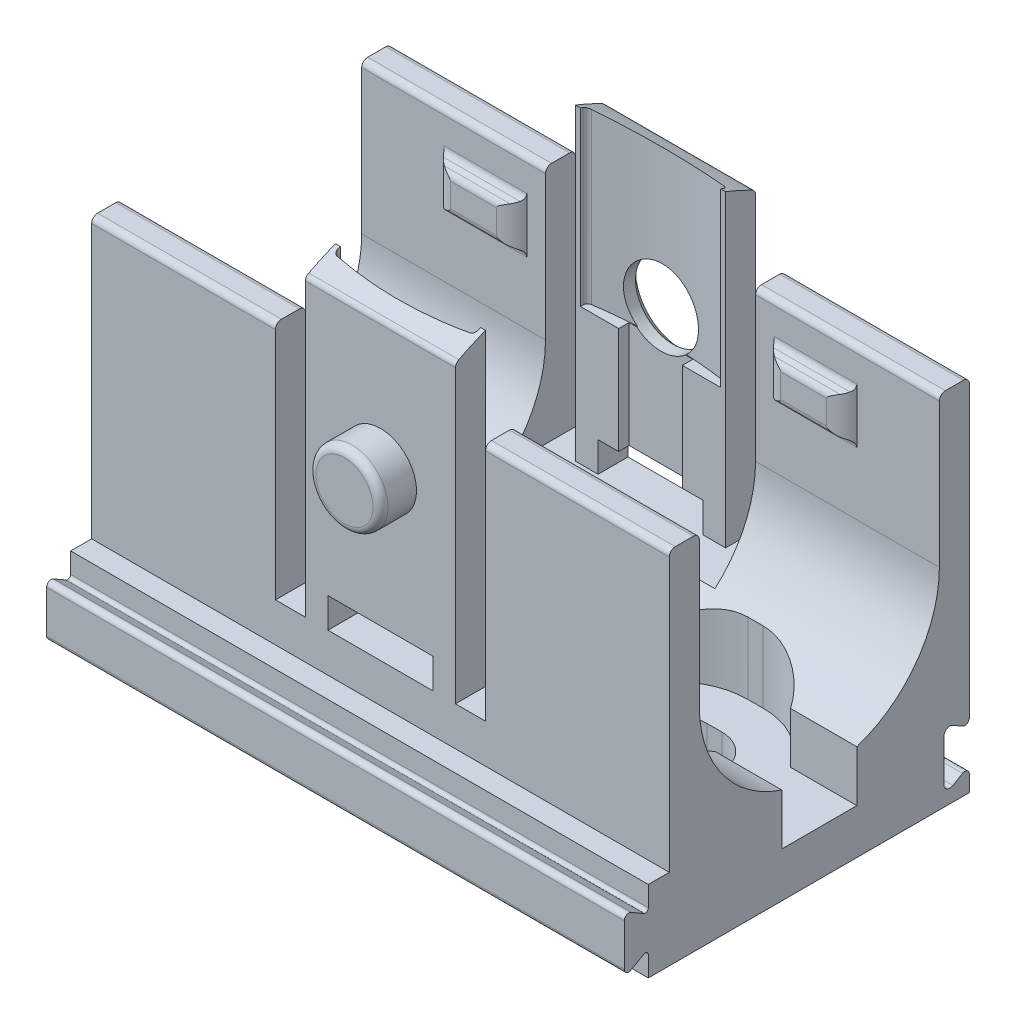
from build123d import *

# Parameters (mm, degrees)
BOSS_EXTRUDE1_DEPTH      = 19.25
BOSS_EXTRUDE1_DEPTH_BACK = 19.25
CUT_EXTRUDE1_DEPTH       = 12
CUT_EXTRUDE1_DEPTH_BACK  = 12
SKETCH2_W                = 14
SKETCH2_H                = 25
BOSS_EXTRUDE2_DEPTH      = 5
BOSS_EXTRUDE2_DEPTH_BACK = 5
BOSS_EXTRUDE3_DEPTH      = 5
BOSS_EXTRUDE3_DEPTH_BACK = 5
CUT_EXTRUDE2_DEPTH       = 12
CUT_EXTRUDE2_DEPTH_BACK  = 12
SKETCH5_W                = 7
SKETCH5_H                = 2
BOSS_EXTRUDE4_DEPTH      = 5.5
BOSS_EXTRUDE5_DEPTH      = 5.5
BOSS_EXTRUDE6_START      = -5.5
BOSS_EXTRUDE6_DEPTH      = 5.5
BOSS_EXTRUDE7_START      = -5.5
BOSS_EXTRUDE7_DEPTH      = 5.5
CUT_EXTRUDE3_DEPTH       = 7
CUT_EXTRUDE4_DEPTH       = 7
CUT_EXTRUDE5_DEPTH       = 2.5
CUT_EXTRUDE5_DEPTH_BACK  = 2.5
CUT_EXTRUDE6_DEPTH       = 2.5
CUT_EXTRUDE6_DEPTH_BACK  = 2.5
CUT_EXTRUDE7_DEPTH       = 2.5
CUT_EXTRUDE7_DEPTH_BACK  = 2.5
CUT_EXTRUDE8_DEPTH       = 2.5
CUT_EXTRUDE8_DEPTH_BACK  = 2.5
SKETCH18_W               = 36.5
SKETCH18_H               = 15.3
CUT_EXTRUDE9_DEPTH       = 1.5
CUT_EXTRUDE10_DEPTH      = 15
SKETCH20_W               = 4.25
SKETCH20_H               = 17.4
CUT_EXTRUDE11_DEPTH      = 8
CUT_EXTRUDE12_DEPTH      = 7
CUT_EXTRUDE13_DEPTH      = 7
BOSS_EXTRUDE8_DEPTH      = 1.5
CUT_EXTRUDE14_DEPTH      = 4
BOSS_EXTRUDE9_DEPTH      = 1.5


with BuildPart() as part:
    # Sketch1 → Boss-Extrude1 (new, two sides: drawn at the far end of the back side and taken through both)
    with BuildSketch(Plane(origin=(0, 0, 0), x_dir=(0, 0, -1), z_dir=(1, 0, 0)).offset(-BOSS_EXTRUDE1_DEPTH_BACK)):
        with BuildLine():
            Line((-13, 4.104145188), (-13, 1.295854812))
            ThreePointArc((-13, 1.295854812), (-12.85, 1.03604719), (-12.55, 1.03604719))
            Line((-12.55, 1.03604719), (-11.7, 1.526794919))
            ThreePointArc((-11.7, 1.526794919), (-11.5, 1.526794919), (-11.4, 1.353589838))
            Line((-11.4, 1.353589838), (-11.4, 0))
            Line((-11.4, 0), (10, 0))
            Line((10, 0), (10, 1.080384758))
            ThreePointArc((10, 1.080384758), (9.85, 1.340192379), (9.55, 1.340192379))
            Line((9.55, 1.340192379), (8.9, 0.964914704))
            ThreePointArc((8.9, 0.964914704), (8.5, 0.964914704), (8.3, 1.311324865))
            Line((8.3, 1.311324865), (8.3, 4.088675135))
            ThreePointArc((8.3, 4.088675135), (8.5, 4.435085296), (8.9, 4.435085296))
            Line((8.9, 4.435085296), (9.55, 4.059807621))
            ThreePointArc((9.55, 4.059807621), (9.85, 4.059807621), (10, 4.319615242))
            Line((10, 4.319615242), (10, 23.6))
            ThreePointArc((10, 23.6), (9.882842712, 23.882842712), (9.6, 24))
            Line((9.6, 24), (8.4, 24))
            ThreePointArc((8.4, 24), (8.117157288, 23.882842712), (8, 23.6))
            Line((8, 23.6), (8, 14))
            ThreePointArc((8, 14), (0, 6), (-8, 14))
            Line((-8, 14), (-8, 23.6))
            ThreePointArc((-8, 23.6), (-8.117157288, 23.882842712), (-8.4, 24))
            Line((-8.4, 24), (-9.6, 24))
            ThreePointArc((-9.6, 24), (-9.882842712, 23.882842712), (-10, 23.6))
            Line((-10, 23.6), (-10, 5.4))
            Line((-10, 5.4), (-11.4, 5.4))
            Line((-11.4, 5.4), (-11.4, 4.046410162))
            ThreePointArc((-11.4, 4.046410162), (-11.5, 3.873205081), (-11.7, 3.873205081))
            Line((-11.7, 3.873205081), (-12.55, 4.36395281))
            ThreePointArc((-12.55, 4.36395281), (-12.85, 4.36395281), (-13, 4.104145188))
        make_face()
    extrude(amount=BOSS_EXTRUDE1_DEPTH + BOSS_EXTRUDE1_DEPTH_BACK)

    # Sketch2 → Cut-Extrude1 (cut, two sides: drawn at the far end of the back side and taken through both)
    with BuildSketch(Plane.XY.offset(-CUT_EXTRUDE1_DEPTH_BACK)):
        with Locations((0, 20.5)):
            Rectangle(SKETCH2_W, SKETCH2_H)
    extrude(amount=CUT_EXTRUDE1_DEPTH + CUT_EXTRUDE1_DEPTH_BACK, mode=Mode.SUBTRACT)

    # Sketch3 → Boss-Extrude2 (add, two sides: drawn at the far end of the back side and taken through both)
    with BuildSketch(Plane(origin=(0, 0, 0), x_dir=(0, 0, -1), z_dir=(1, 0, 0)).offset(-BOSS_EXTRUDE2_DEPTH_BACK)):
        with BuildLine():
            Line((8, 28.563897926), (8, 8))
            Line((8, 8), (10, 8))
            Line((10, 8), (10, 27.401851761))
            ThreePointArc((10, 27.401851761), (9.940919964, 27.611073122), (9.78113211, 27.758490456))
            ThreePointArc((9.78113211, 27.758490456), (8.89968174, 28.181353229), (8, 28.563897926))
        make_face()
    extrude(amount=BOSS_EXTRUDE2_DEPTH + BOSS_EXTRUDE2_DEPTH_BACK)

    # Sketch4 → Boss-Extrude3 (add, two sides: drawn at the far end of the back side and taken through both)
    with BuildSketch(Plane(origin=(0, 0, 0), x_dir=(0, 0, -1), z_dir=(1, 0, 0)).offset(-BOSS_EXTRUDE3_DEPTH_BACK)):
        with BuildLine():
            Line((-10, 27.401851761), (-10, 8))
            Line((-10, 8), (-8, 8))
            Line((-8, 8), (-8, 28.563897926))
            ThreePointArc((-8, 28.563897926), (-8.899681723, 28.181353237), (-9.781132075, 27.758490474))
            ThreePointArc((-9.781132075, 27.758490474), (-9.940919954, 27.611073139), (-10, 27.401851761))
        make_face()
    extrude(amount=BOSS_EXTRUDE3_DEPTH + BOSS_EXTRUDE3_DEPTH_BACK)

    # Sketch5 → Cut-Extrude2 (cut, two sides: drawn at the far end of the back side and taken through both)
    with BuildSketch(Plane.XY.offset(-CUT_EXTRUDE2_DEPTH_BACK)):
        with Locations((0, 9)):
            Rectangle(SKETCH5_W, SKETCH5_H)
    extrude(amount=CUT_EXTRUDE2_DEPTH + CUT_EXTRUDE2_DEPTH_BACK, mode=Mode.SUBTRACT)

    # Sketch6 → Revolve1 (revolve)
    with BuildSketch(Plane(origin=(0, 0, 0), x_dir=(0, 0, -1), z_dir=(1, 0, 0))):
        with BuildLine():
            Line((-12.4, 19), (-12.4, 20.9))
            ThreePointArc((-12.4, 20.9), (-12.253553391, 21.253553391), (-11.9, 21.4))
            Line((-11.9, 21.4), (-10, 21.4))
            Line((-10, 21.4), (-10, 19))
            Line((-10, 19), (-12.4, 19))
        make_face()
    revolve(axis=Axis((0, 19, 10), (0, 0, 1)))

    # Sketch7 → Cut-Revolve1 (revolve, cut)
    with BuildSketch(Plane(origin=(0, 0, 0), x_dir=(0, 0, -1), z_dir=(1, 0, 0))):
        Polygon((8, 19), (8, 21.5), (9.5, 21.5), (10, 22), (10, 19), align=None)
    revolve(axis=Axis((0, 19, -10), (0, 0, 1)), mode=Mode.SUBTRACT)

    # Sketch8 → Boss-Extrude4 (add)
    with BuildSketch(Plane(origin=(8.25, 0, 0), x_dir=(0, 0, -1), z_dir=(1, 0, 0))):
        with BuildLine():
            Line((7.2, 20.79944465), (7.2, 19.20055535))
            ThreePointArc((7.2, 19.20055535), (7.266987298, 18.95055535), (7.45, 18.767542648))
            Line((7.45, 18.767542648), (7.75, 18.594337567))
            ThreePointArc((7.75, 18.594337567), (7.933012702, 18.411324865), (8, 18.161324865))
            Line((8, 18.161324865), (8, 21.838675135))
            ThreePointArc((8, 21.838675135), (7.933012702, 21.588675135), (7.75, 21.405662433))
            Line((7.75, 21.405662433), (7.45, 21.232457352))
            ThreePointArc((7.45, 21.232457352), (7.266987298, 21.04944465), (7.2, 20.79944465))
        make_face()
    extrude(amount=BOSS_EXTRUDE4_DEPTH)

    # Sketch9 → Boss-Extrude5 (add)
    with BuildSketch(Plane(origin=(8.25, 0, 0), x_dir=(0, 0, -1), z_dir=(1, 0, 0))):
        with BuildLine():
            Line((-7.75, 18.594337567), (-7.45, 18.767542648))
            ThreePointArc((-7.45, 18.767542648), (-7.266987298, 18.95055535), (-7.2, 19.20055535))
            Line((-7.2, 19.20055535), (-7.2, 20.79944465))
            ThreePointArc((-7.2, 20.79944465), (-7.266987298, 21.04944465), (-7.45, 21.232457352))
            Line((-7.45, 21.232457352), (-7.75, 21.405662433))
            ThreePointArc((-7.75, 21.405662433), (-7.933012702, 21.588675135), (-8, 21.838675135))
            Line((-8, 21.838675135), (-8, 18.161324865))
            ThreePointArc((-8, 18.161324865), (-7.933012702, 18.411324865), (-7.75, 18.594337567))
        make_face()
    extrude(amount=BOSS_EXTRUDE5_DEPTH)

    # Sketch10 → Boss-Extrude6 (add)
    with BuildSketch(Plane(origin=(-8.25, 0, 0), x_dir=(0, 0, -1), z_dir=(1, 0, 0)).offset(BOSS_EXTRUDE6_START)):
        with BuildLine():
            Line((7.2, 20.79944465), (7.2, 19.20055535))
            ThreePointArc((7.2, 19.20055535), (7.266987298, 18.95055535), (7.45, 18.767542648))
            Line((7.45, 18.767542648), (7.75, 18.594337567))
            ThreePointArc((7.75, 18.594337567), (7.933012702, 18.411324865), (8, 18.161324865))
            Line((8, 18.161324865), (8, 21.838675135))
            ThreePointArc((8, 21.838675135), (7.933012702, 21.588675135), (7.75, 21.405662433))
            Line((7.75, 21.405662433), (7.45, 21.232457352))
            ThreePointArc((7.45, 21.232457352), (7.266987298, 21.04944465), (7.2, 20.79944465))
        make_face()
    extrude(amount=BOSS_EXTRUDE6_DEPTH)

    # Sketch11 → Boss-Extrude7 (add)
    with BuildSketch(Plane(origin=(-8.25, 0, 0), x_dir=(0, 0, -1), z_dir=(1, 0, 0)).offset(BOSS_EXTRUDE7_START)):
        with BuildLine():
            Line((-7.75, 18.594337567), (-7.45, 18.767542648))
            ThreePointArc((-7.45, 18.767542648), (-7.266987298, 18.95055535), (-7.2, 19.20055535))
            Line((-7.2, 19.20055535), (-7.2, 20.79944465))
            ThreePointArc((-7.2, 20.79944465), (-7.266987298, 21.04944465), (-7.45, 21.232457352))
            Line((-7.45, 21.232457352), (-7.75, 21.405662433))
            ThreePointArc((-7.75, 21.405662433), (-7.933012702, 21.588675135), (-8, 21.838675135))
            Line((-8, 21.838675135), (-8, 18.161324865))
            ThreePointArc((-8, 18.161324865), (-7.933012702, 18.411324865), (-7.75, 18.594337567))
        make_face()
    extrude(amount=BOSS_EXTRUDE7_DEPTH)

    # Sketch12 → Cut-Extrude3 (cut)
    with BuildSketch(Plane(origin=(0, 3, 0), x_dir=(1, 0, 0), z_dir=(0, 1, 0))):
        with BuildLine():
            Line((9.5, -5), (10.5, -5))
            ThreePointArc((10.5, -5), (13, -4.330127019), (14.830127019, -2.5))
            Line((14.830127019, -2.5), (19.25, -2.5))
            Line((19.25, -2.5), (19.25, 2.5))
            Line((19.25, 2.5), (14.830127019, 2.5))
            ThreePointArc((14.830127019, 2.5), (13, 4.330127019), (10.5, 5))
            Line((10.5, 5), (9.5, 5))
            ThreePointArc((9.5, 5), (4.5, 0), (9.5, -5))
        make_face()
    extrude(amount=CUT_EXTRUDE3_DEPTH, mode=Mode.SUBTRACT)

    # Sketch13 → Cut-Extrude4 (cut)
    with BuildSketch(Plane(origin=(0, 3, 0), x_dir=(1, 0, 0), z_dir=(0, 1, 0))):
        with BuildLine():
            Line((-19.25, -2.5), (-14.582575695, -2.5))
            ThreePointArc((-14.582575695, -2.5), (-8.978451782, -5.394531565), (-5, -0.5))
            Line((-5, -0.5), (-5, 0.5))
            ThreePointArc((-5, 0.5), (-8.978451782, 5.394531565), (-14.582575695, 2.5))
            Line((-14.582575695, 2.5), (-19.25, 2.5))
            Line((-19.25, 2.5), (-19.25, -2.5))
        make_face()
    extrude(amount=CUT_EXTRUDE4_DEPTH, mode=Mode.SUBTRACT)

    # Sketch14 → Cut-Extrude5 (cut, two sides: drawn at the far end of the back side and taken through both)
    with BuildSketch(Plane(origin=(0, 20, 0), x_dir=(1, 0, 0), z_dir=(0, 1, 0)).offset(-CUT_EXTRUDE5_DEPTH_BACK)):
        with BuildLine():
            Line((8.25, 8), (8.25, 5))
            Line((8.25, 5), (13.75, 5))
            Line((13.75, 5), (13.75, 8))
            ThreePointArc((13.75, 8), (13.222976482, 7.470144004), (12.526181403, 7.2))
            Line((12.526181403, 7.2), (9.473818597, 7.2))
            ThreePointArc((9.473818597, 7.2), (8.777023518, 7.470144004), (8.25, 8))
        make_face()
    extrude(amount=CUT_EXTRUDE5_DEPTH + CUT_EXTRUDE5_DEPTH_BACK, mode=Mode.SUBTRACT)

    # Sketch15 → Cut-Extrude6 (cut, two sides: drawn at the far end of the back side and taken through both)
    with BuildSketch(Plane(origin=(0, 20, 0), x_dir=(1, 0, 0), z_dir=(0, 1, 0)).offset(-CUT_EXTRUDE6_DEPTH_BACK)):
        with BuildLine():
            Line((-13.75, 8), (-13.75, 5))
            Line((-13.75, 5), (-8.25, 5))
            Line((-8.25, 5), (-8.25, 8))
            ThreePointArc((-8.25, 8), (-8.777023518, 7.470144004), (-9.473818597, 7.2))
            Line((-9.473818597, 7.2), (-12.526181403, 7.2))
            ThreePointArc((-12.526181403, 7.2), (-13.222976482, 7.470144004), (-13.75, 8))
        make_face()
    extrude(amount=CUT_EXTRUDE6_DEPTH + CUT_EXTRUDE6_DEPTH_BACK, mode=Mode.SUBTRACT)

    # Sketch16 → Cut-Extrude7 (cut, two sides: drawn at the far end of the back side and taken through both)
    with BuildSketch(Plane(origin=(0, 20, 0), x_dir=(1, 0, 0), z_dir=(0, 1, 0)).offset(-CUT_EXTRUDE7_DEPTH_BACK)):
        with BuildLine():
            Line((9.473818597, -7.2), (12.526181403, -7.2))
            ThreePointArc((12.526181403, -7.2), (13.222976482, -7.470144004), (13.75, -8))
            Line((13.75, -8), (13.75, -5))
            Line((13.75, -5), (8.25, -5))
            Line((8.25, -5), (8.25, -8))
            ThreePointArc((8.25, -8), (8.777023518, -7.470144004), (9.473818597, -7.2))
        make_face()
    extrude(amount=CUT_EXTRUDE7_DEPTH + CUT_EXTRUDE7_DEPTH_BACK, mode=Mode.SUBTRACT)

    # Sketch17 → Cut-Extrude8 (cut, two sides: drawn at the far end of the back side and taken through both)
    with BuildSketch(Plane(origin=(0, 20, 0), x_dir=(1, 0, 0), z_dir=(0, 1, 0)).offset(-CUT_EXTRUDE8_DEPTH_BACK)):
        with BuildLine():
            Line((-12.526181403, -7.2), (-9.473818597, -7.2))
            ThreePointArc((-9.473818597, -7.2), (-8.777023518, -7.470144004), (-8.25, -8))
            Line((-8.25, -8), (-8.25, -5))
            Line((-8.25, -5), (-13.75, -5))
            Line((-13.75, -5), (-13.75, -8))
            ThreePointArc((-13.75, -8), (-13.222976482, -7.470144004), (-12.526181403, -7.2))
        make_face()
    extrude(amount=CUT_EXTRUDE8_DEPTH + CUT_EXTRUDE8_DEPTH_BACK, mode=Mode.SUBTRACT)

    # Sketch18 → Cut-Extrude9 (cut)
    with BuildSketch(Plane(origin=(0, 0, 0), x_dir=(1, 0, 0), z_dir=(0, 1, 0))):
        with Locations((0, -0.85)):
            Rectangle(SKETCH18_W, SKETCH18_H)
    extrude(amount=CUT_EXTRUDE9_DEPTH, mode=Mode.SUBTRACT)

    # Sketch19 → Cut-Extrude10 (cut)
    with BuildSketch(Plane(origin=(0, 17.1, 0), x_dir=(1, 0, 0), z_dir=(0, 1, 0))):
        with BuildLine():
            Line((-4.675, 8.178190868), (-4.675, -8.178190868))
            ThreePointArc((-4.675, -8.178190868), (-4.6021221, -8.374189724), (-4.418896321, -8.474962013))
            ThreePointArc((-4.418896321, -8.474962013), (0, -8.8), (4.418896321, -8.474962013))
            ThreePointArc((4.418896321, -8.474962013), (4.6021221, -8.374189724), (4.675, -8.178190868))
            Line((4.675, -8.178190868), (4.675, 8.178190868))
            ThreePointArc((4.675, 8.178190868), (4.6021221, 8.374189724), (4.418896321, 8.474962013))
            ThreePointArc((4.418896321, 8.474962013), (0, 8.8), (-4.418896321, 8.474962013))
            ThreePointArc((-4.418896321, 8.474962013), (-4.6021221, 8.374189724), (-4.675, 8.178190868))
        make_face()
    extrude(amount=CUT_EXTRUDE10_DEPTH, mode=Mode.SUBTRACT)

    # Sketch20 → Cut-Extrude11 (cut)
    with BuildSketch(Plane(origin=(0, 17.1, 0), x_dir=(1, 0, 0), z_dir=(0, 1, 0))):
        Rectangle(SKETCH20_W, SKETCH20_H)
    extrude(amount=-CUT_EXTRUDE11_DEPTH, mode=Mode.SUBTRACT)

    # Sketch21 → Cut-Extrude12 (cut)
    with BuildSketch(Plane(origin=(0, 5, 0), x_dir=(1, 0, 0), z_dir=(0, 1, 0))):
        with BuildLine():
            Line((-1.125, -6.25), (1.125, -6.25))
            ThreePointArc((1.125, -6.25), (1.832106781, -5.957106781), (2.125, -5.25))
            Line((2.125, -5.25), (2.125, 5.25))
            ThreePointArc((2.125, 5.25), (1.832106781, 5.957106781), (1.125, 6.25))
            Line((1.125, 6.25), (-1.125, 6.25))
            ThreePointArc((-1.125, 6.25), (-1.832106781, 5.957106781), (-2.125, 5.25))
            Line((-2.125, 5.25), (-2.125, -5.25))
            ThreePointArc((-2.125, -5.25), (-1.832106781, -5.957106781), (-1.125, -6.25))
        make_face()
    extrude(amount=CUT_EXTRUDE12_DEPTH, mode=Mode.SUBTRACT)

    # Sketch22 → Cut-Extrude13 (cut)
    with BuildSketch(Plane(origin=(0, 0, 0), x_dir=(1, 0, 0), z_dir=(0, 1, 0))):
        with BuildLine():
            Line((9.5, -2.25), (10.5, -2.25))
            ThreePointArc((10.5, -2.25), (12.75, 0), (10.5, 2.25))
            Line((10.5, 2.25), (9.5, 2.25))
            ThreePointArc((9.5, 2.25), (7.25, 0), (9.5, -2.25))
        make_face()
    extrude(amount=CUT_EXTRUDE13_DEPTH, mode=Mode.SUBTRACT)

    # Sketch23 → Boss-Extrude8 (add)
    with BuildSketch(Plane(origin=(0, 0, 0), x_dir=(1, 0, 0), z_dir=(0, 1, 0))):
        with BuildLine():
            Line((9.5, -3.75), (10.5, -3.75))
            ThreePointArc((10.5, -3.75), (14.25, 0), (10.5, 3.75))
            Line((10.5, 3.75), (9.5, 3.75))
            ThreePointArc((9.5, 3.75), (5.75, 0), (9.5, -3.75))
        make_face()
        with BuildLine():
            Line((9.5, -2.25), (10.5, -2.25))
            ThreePointArc((10.5, -2.25), (12.75, 0), (10.5, 2.25))
            Line((10.5, 2.25), (9.5, 2.25))
            ThreePointArc((9.5, 2.25), (7.25, 0), (9.5, -2.25))
        make_face(mode=Mode.SUBTRACT)
    extrude(amount=BOSS_EXTRUDE8_DEPTH)

    # Sketch24 → Cut-Extrude14 (cut)
    with BuildSketch(Plane(origin=(0, 0, 0), x_dir=(1, 0, 0), z_dir=(0, 1, 0))):
        with BuildLine():
            Line((-12.25, 0.5), (-12.25, -0.5))
            ThreePointArc((-12.25, -0.5), (-10, -2.75), (-7.75, -0.5))
            Line((-7.75, -0.5), (-7.75, 0.5))
            ThreePointArc((-7.75, 0.5), (-10, 2.75), (-12.25, 0.5))
        make_face()
    extrude(amount=CUT_EXTRUDE14_DEPTH, mode=Mode.SUBTRACT)

    # Sketch25 → Boss-Extrude9 (add)
    with BuildSketch(Plane(origin=(0, 0, 0), x_dir=(1, 0, 0), z_dir=(0, 1, 0))):
        with BuildLine():
            Line((-6.25, -0.5), (-6.25, 0.5))
            ThreePointArc((-6.25, 0.5), (-10, 4.25), (-13.75, 0.5))
            Line((-13.75, 0.5), (-13.75, -0.5))
            ThreePointArc((-13.75, -0.5), (-10, -4.25), (-6.25, -0.5))
        make_face()
        with BuildLine():
            Line((-7.75, -0.5), (-7.75, 0.5))
            ThreePointArc((-7.75, 0.5), (-10, 2.75), (-12.25, 0.5))
            Line((-12.25, 0.5), (-12.25, -0.5))
            ThreePointArc((-12.25, -0.5), (-10, -2.75), (-7.75, -0.5))
        make_face(mode=Mode.SUBTRACT)
    extrude(amount=BOSS_EXTRUDE9_DEPTH)


solid = part.part
